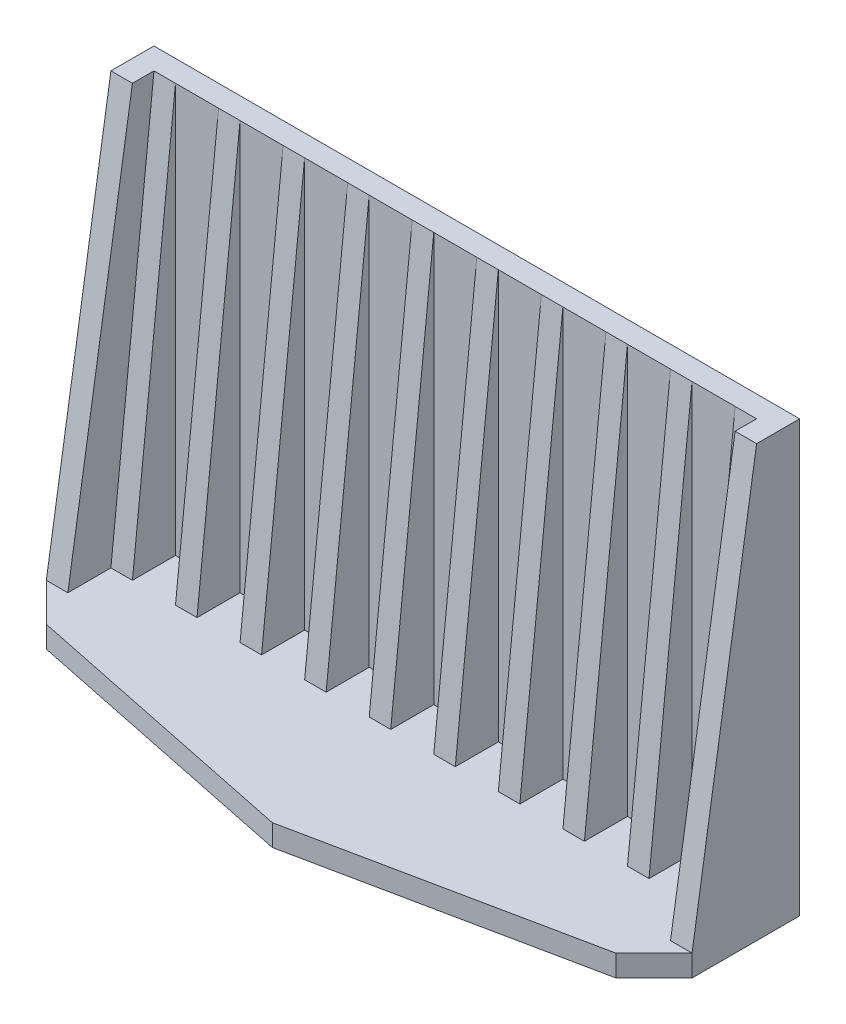
from build123d import *

# Parameters (mm, degrees)
CROQUIS1_W              = 1
CROQUIS1_H              = 20
SALIENTE_EXTRUIR1_DEPTH = 30
CROQUIS2_W              = 4
CROQUIS2_H              = 1
SALIENTE_EXTRUIR3_DEPTH = 30
SALIENTE_EXTRUIR4_DEPTH = 1
SALIENTE_EXTRUIR5_DEPTH = 1
SALIENTE_EXTRUIR7_DEPTH = 1
NERVIO4_REACH           = 38.239
CROQUIS8_WALL_W         = 93.582555916
CROQUIS8_WALL_H         = 1
MATRIZL12_COUNT         = 9
MATRIZL12_PITCH         = 3
NERVIO5_REACH           = 38.239
CROQUIS10_WALL_W        = 93.582555916
CROQUIS10_WALL_H        = 1


with BuildPart() as part:
    # Croquis1 → Saliente-Extruir1 (new body)
    with BuildSketch(Plane(origin=(0, 0, 0), x_dir=(0, 0, -1), z_dir=(1, 0, 0))):
        with Locations((0.5, 10)):
            Rectangle(CROQUIS1_W, CROQUIS1_H)
    extrude(amount=-SALIENTE_EXTRUIR1_DEPTH)

    # Croquis2 → Saliente-Extruir3 (add)
    with BuildSketch(Plane(origin=(0, 0, 0), x_dir=(0, 0, -1), z_dir=(1, 0, 0))):
        with Locations((-2, 0.5)):
            Rectangle(CROQUIS2_W, CROQUIS2_H)
    extrude(amount=-SALIENTE_EXTRUIR3_DEPTH)

    # Croquis3 → Saliente-Extruir4 (add)
    with BuildSketch(Plane(origin=(0, 0, 0), x_dir=(0, 0, -1), z_dir=(1, 0, 0))):
        Polygon((-4, 1), (-1, 20), (0, 20), (0, 1), align=None)
    extrude(amount=-SALIENTE_EXTRUIR4_DEPTH)

    # Croquis6 → Saliente-Extruir5 (add)
    with BuildSketch(Plane.ZY.offset(30)):
        Polygon((0, 20), (1, 20), (4, 1), (0, 1), align=None)
    extrude(amount=-SALIENTE_EXTRUIR5_DEPTH)

    # Croquis7 → Saliente-Extruir7 (add)
    with BuildSketch(Plane(origin=(0, 1, 0), x_dir=(1, 0, 0), z_dir=(0, 1, 0))):
        Polygon((-30, -4), (-28.232233047, -5.767766953), (-15, -8.5), (-1.767766953, -5.767766953), (0, -4), align=None)
    extrude(amount=-SALIENTE_EXTRUIR7_DEPTH)

    # Croquis8 wall → Nervio4 (add, up to next)
    with BuildSketch(Plane(origin=(-29, 10.5, 1), x_dir=(0, 0.994505452921, -0.104684784518), z_dir=(0, 0.104684784518, 0.994505452921)), mode=Mode.PRIVATE) as nervio4_sk1:
        with Locations((0, -0.5)):
            Rectangle(CROQUIS8_WALL_W, CROQUIS8_WALL_H)
    nervio4_tool1 = extrude(nervio4_sk1.sketch, amount=-NERVIO4_REACH, mode=Mode.PRIVATE) - part.part
    nervio4 = nervio4_tool1.solids().sort_by_distance((-29, 10.5, 1))[0]
    add(nervio4)

    # MatrizL12: Nervio4 ×9
    with Locations(*[(i * MATRIZL12_PITCH, 0, 0) for i in range(1, MATRIZL12_COUNT)]):
        add(nervio4)

    # Croquis10 wall → Nervio5 (add, up to next)
    with BuildSketch(Plane(origin=(-1, 10.5, 1), x_dir=(0, 0.994505452921, -0.104684784518), z_dir=(0, -0.104684784518, -0.994505452921)), mode=Mode.PRIVATE) as nervio5_sk1:
        with Locations((0, -0.5)):
            Rectangle(CROQUIS10_WALL_W, CROQUIS10_WALL_H)
    nervio5_tool1 = extrude(nervio5_sk1.sketch, amount=NERVIO5_REACH, mode=Mode.PRIVATE) - part.part
    add(nervio5_tool1.solids().sort_by_distance((-1, 10.5, 1))[0])


solid = part.part
